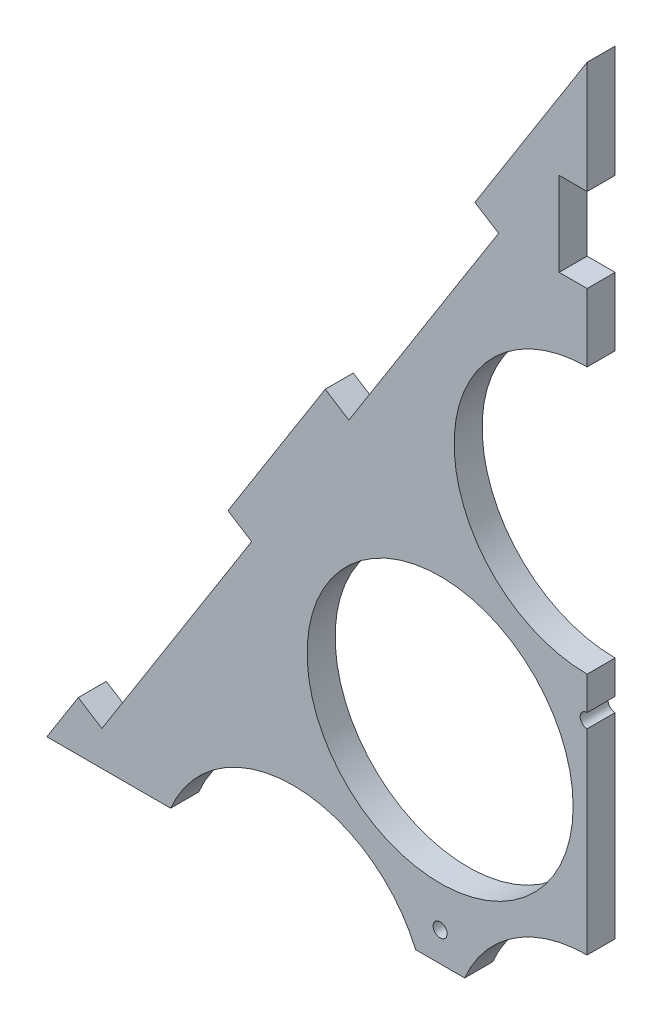
from build123d import *

# Parameters (mm, degrees)
ESQUISSE1_R             = 47.5
BOSS_EXTRU_1_DEPTH      = 10
ESQUISSE3_W             = 100
ESQUISSE3_H             = 10
ENL_V_MAT_EXTRU_1_DEPTH = 11
ESQUISSE4_R             = 2.5
ENL_V_MAT_EXTRU_2_DEPTH = 11
ESQUISSE6_W             = 75
ESQUISSE6_H             = 120
BOSS_EXTRU_2_DEPTH      = 10
ESQUISSE7_W             = 10
ESQUISSE7_H             = 50
ESQUISSE7_W_2           = 30
ESQUISSE7_H_2           = 9.570800355
ENL_V_MAT_EXTRU_3_DEPTH = 10
ENL_V_MAT_EXTRU_6_DEPTH = 10
ESQUISSE12_W            = 10
ESQUISSE12_H            = 30
ENL_V_MAT_EXTRU_7_DEPTH = 10


with BuildPart() as part:
    # Esquisse1 → Boss.-Extru.1 (new body)
    with BuildSketch(Plane.XY):
        Polygon((-310, -75.642859016), (0, 414.561180135), (310, -75.642859016), align=None)
        with Locations((-157.5, 0)):
            Circle(ESQUISSE1_R, mode=Mode.SUBTRACT)
        with Locations((-52.5, 0)):
            Circle(ESQUISSE1_R, mode=Mode.SUBTRACT)
        with Locations((52.5, 0)):
            Circle(ESQUISSE1_R, mode=Mode.SUBTRACT)
        with Locations((157.5, 0)):
            Circle(ESQUISSE1_R, mode=Mode.SUBTRACT)
        with Locations((-105, 90.932667397)):
            Circle(ESQUISSE1_R, mode=Mode.SUBTRACT)
        with Locations((0, 90.932667397)):
            Circle(ESQUISSE1_R, mode=Mode.SUBTRACT)
        with Locations((105, 90.932667397)):
            Circle(ESQUISSE1_R, mode=Mode.SUBTRACT)
        with Locations((-52.5, 181.865334795)):
            Circle(ESQUISSE1_R, mode=Mode.SUBTRACT)
        with Locations((52.5, 181.865334795)):
            Circle(ESQUISSE1_R, mode=Mode.SUBTRACT)
        with Locations((0, 272.798002192)):
            Circle(ESQUISSE1_R, mode=Mode.SUBTRACT)
    extrude(amount=BOSS_EXTRU_1_DEPTH)

    # Esquisse3 → Enlèv. mat.-Extru.1 (cut, through all)
    with BuildSketch(Plane.XY.offset(10)):
        Polygon((-269.913793103, -12.254405678), (-261.461999325, -17.599233264), (-208.013723463, 66.918704521), (-216.465517241, 72.263532107), align=None)
        Polygon((-181.724137931, 127.200191667), (-173.272344153, 121.855364081), (-119.82406829, 206.373301865), (-128.275862069, 211.718129452), align=None)
        Polygon((-93.534482759, 266.654789012), (-85.08268898, 261.309961425), (-31.634413118, 345.82789921), (-40.086206897, 351.172726796), align=None)
        Polygon((269.913793103, -12.254405678), (261.461999325, -17.599233264), (208.013723463, 66.918704521), (216.465517241, 72.263532107), align=None)
        Polygon((181.724137931, 127.200191667), (173.272344153, 121.855364081), (119.82406829, 206.373301865), (128.275862069, 211.718129452), align=None)
        Polygon((93.534482759, 266.654789012), (85.08268898, 261.309961425), (31.634413118, 345.82789921), (40.086206897, 351.172726796), align=None)
        with Locations((-160, -70.642859016)):
            Rectangle(ESQUISSE3_W, ESQUISSE3_H)
        with Locations((160, -70.642859016)):
            Rectangle(ESQUISSE3_W, ESQUISSE3_H)
    extrude(amount=-ENL_V_MAT_EXTRU_1_DEPTH, mode=Mode.SUBTRACT)

    # Esquisse4 → Enlèv. mat.-Extru.2 (cut, through all)
    with BuildSketch(Plane.XY.offset(10)):
        with Locations((-157.5, -55.642859016)):
            Circle(ESQUISSE4_R)
        with Locations((-52.5, -55.642859016)):
            Circle(ESQUISSE4_R)
        with Locations((52.5, -55.642859016)):
            Circle(ESQUISSE4_R)
        with Locations((157.5, -55.642859016)):
            Circle(ESQUISSE4_R)
        with Locations((-105, 29.047375097)):
            Circle(ESQUISSE4_R)
        with Locations((0, 29.047375097)):
            Circle(ESQUISSE4_R)
        with Locations((105, 29.047375097)):
            Circle(ESQUISSE4_R)
        with Locations((-52.5, 119.980042494)):
            Circle(ESQUISSE4_R)
        with Locations((52.5, 119.980042494)):
            Circle(ESQUISSE4_R)
        with Locations((0, 210.912709891)):
            Circle(ESQUISSE4_R)
    extrude(amount=-ENL_V_MAT_EXTRU_2_DEPTH, mode=Mode.SUBTRACT)

    # Esquisse6 → Boss.-Extru.2 (add)
    with BuildSketch(Plane.XY.offset(10)):
        with Locations((0, -135.642859016)):
            Rectangle(ESQUISSE6_W, ESQUISSE6_H)
    extrude(amount=-BOSS_EXTRU_2_DEPTH)

    # Esquisse7 → Enlèv. mat.-Extru.3 (cut)
    with BuildSketch(Plane.XY.offset(10)):
        with Locations((-32.5, -135.642859016)):
            Rectangle(ESQUISSE7_W, ESQUISSE7_H)
        with Locations((1.495284743, -190.857458839)):
            Rectangle(ESQUISSE7_W_2, ESQUISSE7_H_2)
        with Locations((32.5, -135.642859016)):
            Rectangle(ESQUISSE7_W, ESQUISSE7_H)
    extrude(amount=-ENL_V_MAT_EXTRU_3_DEPTH, mode=Mode.SUBTRACT)

    # Esquisse11 → Enlèv. mat.-Extru.6 (cut)
    with BuildSketch(Plane.XY.offset(10)):
        Polygon((0, 414.561180135), (0, 109.461180135), (-346.154388362, 109.461180135), (-346.154388362, -222.549126753), (369.346533709, -222.549126753), (369.346533709, 414.561180135), align=None)
    extrude(amount=-ENL_V_MAT_EXTRU_6_DEPTH, mode=Mode.SUBTRACT)

    # Esquisse12 → Enlèv. mat.-Extru.7 (cut)
    with BuildSketch(Plane.XY.offset(10)):
        with Locations((-5, 359.561180135)):
            Rectangle(ESQUISSE12_W, ESQUISSE12_H)
    extrude(amount=-ENL_V_MAT_EXTRU_7_DEPTH, mode=Mode.SUBTRACT)


solid = part.part
